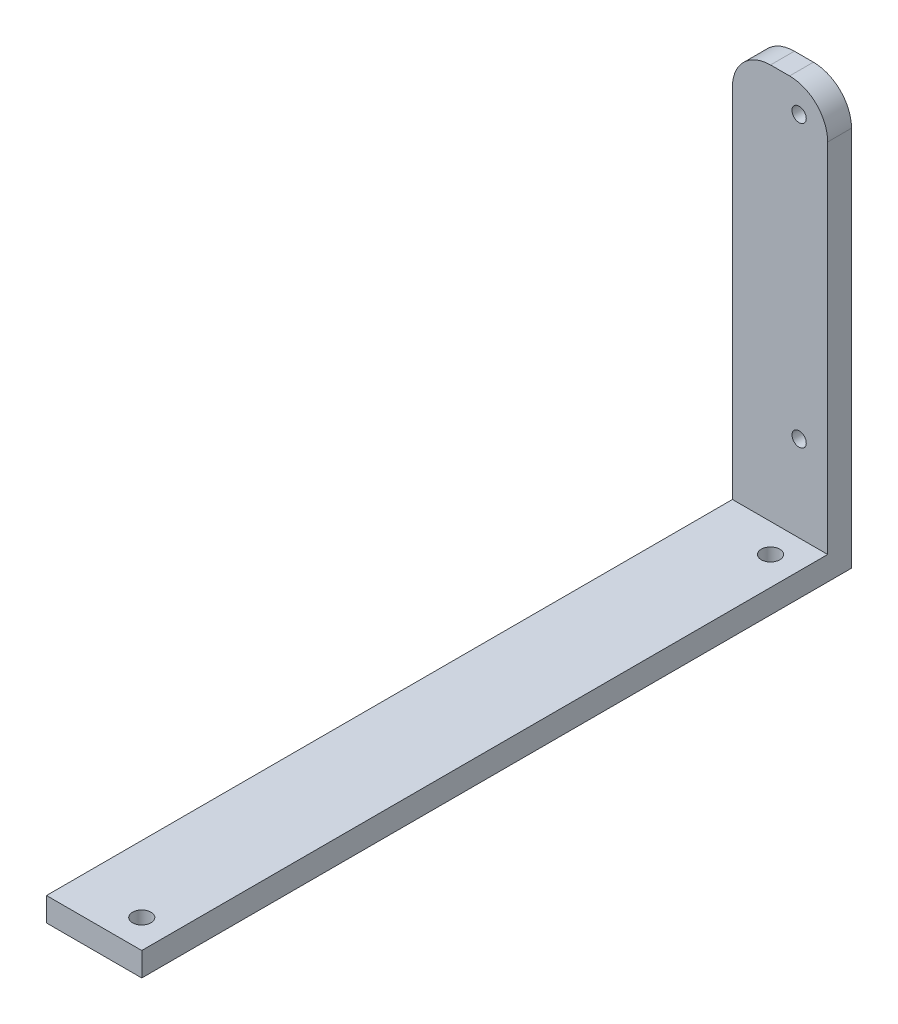
from build123d import *

# Parameters (mm, degrees)
SKETCH1_W           = 20
SKETCH1_H           = 88
SKETCH1_R           = 1.5
BOSS_EXTRUDE1_DEPTH = 5
SKETCH2_W           = 20
SKETCH2_H           = 5
BOSS_EXTRUDE2_DEPTH = 144
FILLET1_R           = 8
SKETCH3_R           = 1.939400698
CUT_EXTRUDE1_DEPTH  = 6


with BuildPart() as part:
    # Sketch1 → Boss-Extrude1 (new body)
    with BuildSketch(Plane.XY):
        with Locations((10, 44)):
            Rectangle(SKETCH1_W, SKETCH1_H)
        with Locations((14, 82)):
            Circle(SKETCH1_R, mode=Mode.SUBTRACT)
        with Locations((14, 23)):
            Circle(SKETCH1_R, mode=Mode.SUBTRACT)
    extrude(amount=BOSS_EXTRUDE1_DEPTH)

    # Sketch2 → Boss-Extrude2 (add)
    with BuildSketch(Plane.XY.offset(5)):
        with Locations((10, 2.5)):
            Rectangle(SKETCH2_W, SKETCH2_H)
    extrude(amount=BOSS_EXTRUDE2_DEPTH)

    # Fillet1
    fillet1_edges = [part.edges().sort_by_distance(p)[0] for p in [
        (20, 88, 2.5),
        (0, 88, 2.5),
    ]]
    fillet(fillet1_edges, radius=FILLET1_R)

    # Sketch3 → Cut-Extrude1 (cut, through all)
    with BuildSketch(Plane(origin=(0, 5, 0), x_dir=(1, 0, 0), z_dir=(0, 1, 0))):
        with Locations((14, -143)):
            Circle(SKETCH3_R)
        with Locations((14, -11)):
            Circle(SKETCH3_R)
    extrude(amount=-CUT_EXTRUDE1_DEPTH, mode=Mode.SUBTRACT)


solid = part.part
